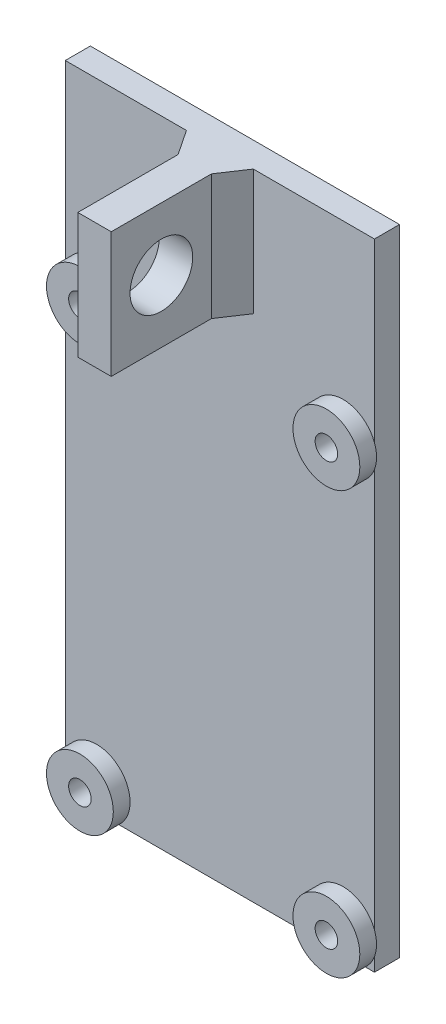
from build123d import *

# Parameters (mm, degrees)
MAIN_SKETCH_W                          = 37
MAIN_SKETCH_H                          = 76
MAIN_EXTRUSION_DEPTH                   = 3
BOARD_FIX_SKETCH_R                     = 4
BOARD_FIX_SKETCH_R_2                   = 1.35
BOARD_FIX_DEPTH                        = 2
JACK_FIX_SKETCH_W                      = 4
JACK_FIX_SKETCH_H                      = 15
JACK_FIX_DEPTH                         = 15
JACK_FIX_HOLE_SKETCH_R                 = 3.75
JACK_FIX_HOLE_DEPTH                    = 21.75
JACK_FIX_REINFORCEMENT_EXTRUSION_DEPTH = 15


with BuildPart() as part:
    # Main-Sketch → Main-Extrusion (new body)
    with BuildSketch(Plane.XY):
        with Locations((18.5, 38)):
            Rectangle(MAIN_SKETCH_W, MAIN_SKETCH_H)
    extrude(amount=MAIN_EXTRUSION_DEPTH)

    # Board-Fix-Sketch → Board-Fix (add)
    with BuildSketch(Plane.XY.offset(3)):
        with Locations((3.75, 3)):
            Circle(BOARD_FIX_SKETCH_R)
        with Locations((3.75, 3)):
            Circle(BOARD_FIX_SKETCH_R_2, mode=Mode.SUBTRACT)
        with Locations((33.25, 3)):
            Circle(BOARD_FIX_SKETCH_R)
        with Locations((33.25, 3)):
            Circle(BOARD_FIX_SKETCH_R_2, mode=Mode.SUBTRACT)
        with Locations((33.25, 53.5)):
            Circle(BOARD_FIX_SKETCH_R)
        with Locations((33.25, 53.5)):
            Circle(BOARD_FIX_SKETCH_R_2, mode=Mode.SUBTRACT)
        with Locations((3.75, 53.5)):
            Circle(BOARD_FIX_SKETCH_R)
        with Locations((3.75, 53.5)):
            Circle(BOARD_FIX_SKETCH_R_2, mode=Mode.SUBTRACT)
    extrude(amount=BOARD_FIX_DEPTH)

    # Jack-Fix-Sketch → Jack-Fix (add)
    with BuildSketch(Plane.XY.offset(3)):
        with Locations((18.5, 68.5)):
            Rectangle(JACK_FIX_SKETCH_W, JACK_FIX_SKETCH_H)
    extrude(amount=JACK_FIX_DEPTH)

    # Jack-Fix-Hole-Sketch → Jack-Fix-Hole (cut, through all)
    with BuildSketch(Plane(origin=(20.5, 0, 0), x_dir=(0, 0, -1), z_dir=(1, 0, 0))):
        with Locations((-12, 68.5)):
            Circle(JACK_FIX_HOLE_SKETCH_R)
    extrude(amount=-JACK_FIX_HOLE_DEPTH, mode=Mode.SUBTRACT)

    # Jack-Fix-Reinforcement-Sketch → Jack-Fix-Reinforcement-Extrusion (add)
    with BuildSketch(Plane(origin=(0, 61, 0), x_dir=(-1, 0, 0), z_dir=(0, -1, 0))):
        Polygon((-22.5, -3), (-14.5, -3), (-16.5, -6), (-20.5, -6), align=None)
    extrude(amount=-JACK_FIX_REINFORCEMENT_EXTRUSION_DEPTH)


solid = part.part
